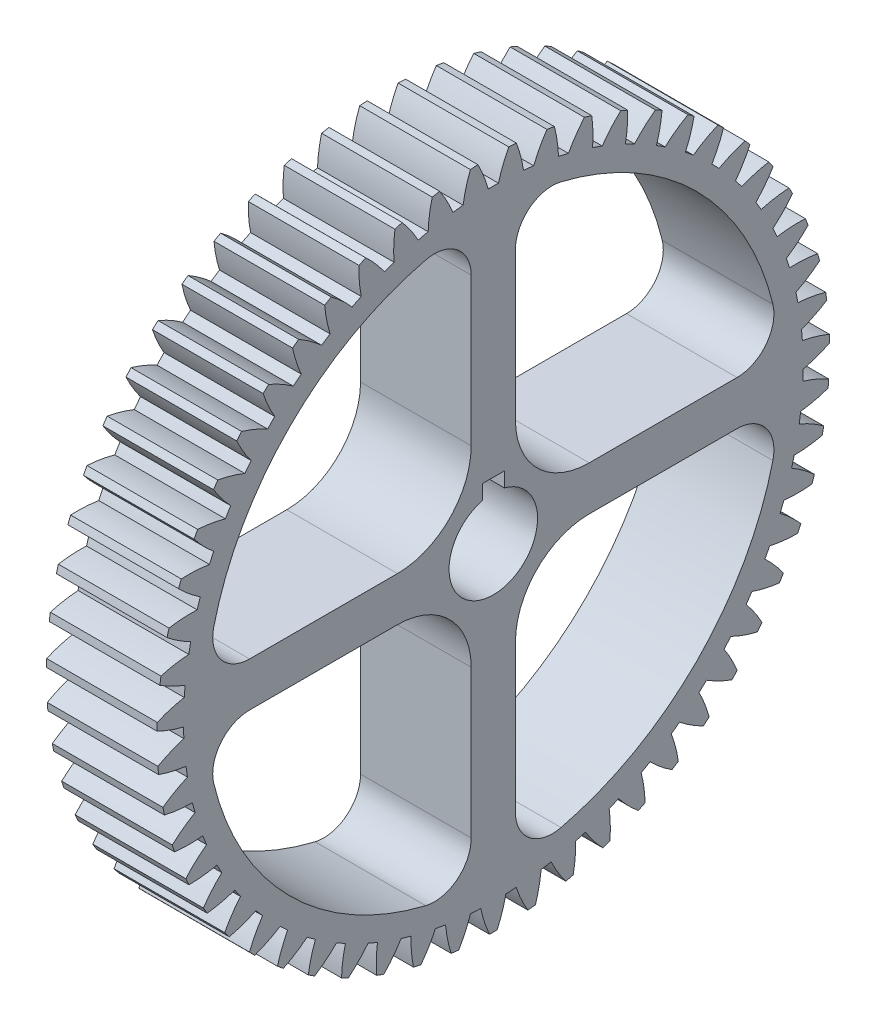
from build123d import *

# Parameters (mm, degrees)
BASPROSKE_W         = 7.5
BASPROSKE_H         = 22.8
TOOTHCUT_DEPTH      = 34.104833484
TEETHCUTS_COUNT     = 55
TEETHCUTS_ANGLE     = 353.454545455
BORSKE_R            = 0.4
BORE_DEPTH          = 50.0000508
SKETCH1_R           = 0.4
BOSS_EXTRUDE1_DEPTH = 7.5
SKETCH2_R           = 19.499
CUT_EXTRUDE1_DEPTH  = 10
BOSS_EXTRUDE2_DEPTH = 7.5
FILLET1_R           = 2.5
CUT_EXTRUDE2_DEPTH  = 34.102485995


with BuildPart() as part:
    # BasProSke → Base-Revolve (revolve)
    with BuildSketch(Plane(origin=(0, 0, 0), x_dir=(1, 0, 0), z_dir=(0, 1, 0)), mode=Mode.PRIVATE) as base_revolve_sk:
        with Locations((3.75, 11.4)):
            Rectangle(BASPROSKE_W, BASPROSKE_H)
    revolve(base_revolve_sk.sketch.rotate(Axis((-10, 0, 0), (1, 0, 0)), 180), axis=Axis((-10, 0, 0), (1, 0, 0)))

    # TooCutSke → ToothCut (cut, through all)
    with BuildSketch(Plane(origin=(0, 0, 0), x_dir=(0, 0, -1), z_dir=(1, 0, 0))):
        with BuildLine():
            ThreePointArc((0.346144751, 20.996146904), (0, 20.999), (-0.346144751, 20.996146904))
            ThreePointArc((-0.346144751, 20.996146904), (-0.652248395, 21.918184567), (-1.058124468, 22.8008609))
            ThreePointArc((-1.058124468, 22.8008609), (0, 22.8254), (1.058124468, 22.8008609))
            ThreePointArc((1.058124468, 22.8008609), (0.652248395, 21.918184567), (0.346144751, 20.996146904))
        make_face()
    toothcut = extrude(amount=TOOTHCUT_DEPTH, mode=Mode.SUBTRACT)

    # TeethCuts: ToothCut ×55 about axis
    teethcuts_axis = Axis((-10, 0, 0), (1, 0, 0))
    for i in range(1, TEETHCUTS_COUNT):
        add(toothcut.rotate(teethcuts_axis, i * TEETHCUTS_ANGLE / (TEETHCUTS_COUNT - 1)), mode=Mode.SUBTRACT)

    # BorSke → Bore (cut, symmetric)
    with BuildSketch(Plane(origin=(0, 0, 0), x_dir=(0, 0, -1), z_dir=(1, 0, 0))):
        with Locations(Location((0, 0, 0), (0, 0, 180))):
            Circle(BORSKE_R)
    extrude(amount=BORE_DEPTH, both=True, mode=Mode.SUBTRACT)

    # Sketch1 → Boss-Extrude1 (add)
    with BuildSketch(Plane(origin=(7.5, 0, 0), x_dir=(0, 0, -1), z_dir=(1, 0, 0))):
        Circle(SKETCH1_R)
    extrude(amount=-BOSS_EXTRUDE1_DEPTH)

    # Sketch2 → Cut-Extrude1 (cut)
    with BuildSketch(Plane(origin=(7.5, 0, 0), x_dir=(0, 0, -1), z_dir=(1, 0, 0))):
        Circle(SKETCH2_R)
    extrude(amount=-CUT_EXTRUDE1_DEPTH, mode=Mode.SUBTRACT)

    # Sketch3 → Boss-Extrude2 (add)
    with BuildSketch(Plane(origin=(7.5, 0, 0), x_dir=(0, 0, -1), z_dir=(1, 0, 0))):
        with BuildLine():
            Line((-19.441219123, -1.5), (-6.5, -1.5))
            ThreePointArc((-6.5, -1.5), (-2.964466094, -2.964466094), (-1.5, -6.5))
            Line((-1.5, -6.5), (-1.5, -19.441219123))
            ThreePointArc((-1.5, -19.441219123), (0, -19.499), (1.5, -19.441219123))
            Line((1.5, -19.441219123), (1.5, -6.5))
            ThreePointArc((1.5, -6.5), (2.964466094, -2.964466094), (6.5, -1.5))
            Line((6.5, -1.5), (19.441219123, -1.5))
            ThreePointArc((19.441219123, -1.5), (19.499, 0), (19.441219123, 1.5))
            Line((19.441219123, 1.5), (6.5, 1.5))
            ThreePointArc((6.5, 1.5), (2.964466094, 2.964466094), (1.5, 6.5))
            Line((1.5, 6.5), (1.5, 19.441219123))
            ThreePointArc((1.5, 19.441219123), (0, 19.499), (-1.5, 19.441219123))
            Line((-1.5, 19.441219123), (-1.5, 6.5))
            ThreePointArc((-1.5, 6.5), (-2.964466094, 2.964466094), (-6.5, 1.5))
            Line((-6.5, 1.5), (-19.441219123, 1.5))
            ThreePointArc((-19.441219123, 1.5), (-19.499, 0), (-19.441219123, -1.5))
        make_face()
    extrude(amount=-BOSS_EXTRUDE2_DEPTH)

    # Fillet1
    fillet1_edges = [part.edges().sort_by_distance(p)[0] for p in [
        (3.75, -1.5, 19.441219123),
        (3.75, 1.5, 19.441219123),
        (3.75, 19.441219123, 1.5),
        (3.75, 19.441219123, -1.5),
        (3.75, 1.5, -19.441219123),
        (3.75, -1.5, -19.441219123),
        (3.75, -19.441219123, -1.5),
        (3.75, -19.441219123, 1.5),
    ]]
    fillet(fillet1_edges, radius=FILLET1_R)

    # Sketch4 → Cut-Extrude2 (cut, through all)
    with BuildSketch(Plane.ZY):
        with BuildLine():
            Line((-0.75, 2.90473751), (-0.75, 3.90473751))
            Line((-0.75, 3.90473751), (0.75, 3.90473751))
            Line((0.75, 3.90473751), (0.75, 2.90473751))
            ThreePointArc((0.75, 2.90473751), (0, -3), (-0.75, 2.90473751))
        make_face()
    extrude(amount=-CUT_EXTRUDE2_DEPTH, mode=Mode.SUBTRACT)


solid = part.part
